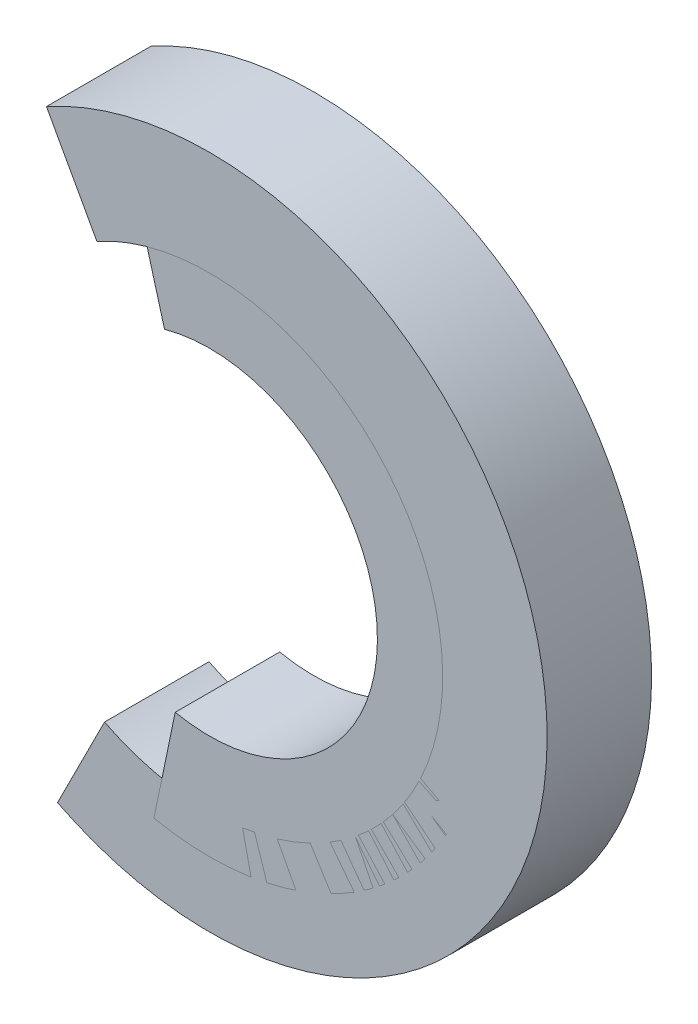
from build123d import *

# Parameters (mm, degrees)
EXTRUDE_THIN2_DEPTH   = 10
EXTRUDE_THIN2_2_DEPTH = 10


with BuildPart() as part:
    # Sketch4 → Extrude-Thin2 (new body)
    with BuildSketch(Plane.XY):
        with BuildLine():
            ThreePointArc((51.430434586, -47.048700863), (83.798011386, -26.698324999), (50.699658978, -7.559440665))
            Line((50.699658978, -7.559440665), (45.872467494, 1.198311466))
            ThreePointArc((45.872467494, 1.198311466), (93.796299525, -26.513299879), (46.930573562, -55.979056442))
            Line((46.930573562, -55.979056442), (51.430434586, -47.048700863))
        make_face()
    extrude(amount=EXTRUDE_THIN2_DEPTH)


with BuildPart() as body_2:
    # Sketch4 → Extrude-Thin2 2 (new body)
    with BuildSketch(Plane.XY):
        with BuildLine():
            ThreePointArc((58.200812032, -42.854949454), (77.548623594, -26.585101854), (57.177856739, -11.615879733))
            Line((57.177856739, -11.615879733), (54.504680696, -1.979794955))
            ThreePointArc((54.504680696, -1.979794955), (87.543266392, -26.257817052), (56.163773668, -52.645275021))
            Line((56.163773668, -52.645275021), (58.200812032, -42.854949454))
        make_face()
    extrude(amount=EXTRUDE_THIN2_2_DEPTH)


solid = Compound([part.part, body_2.part])
